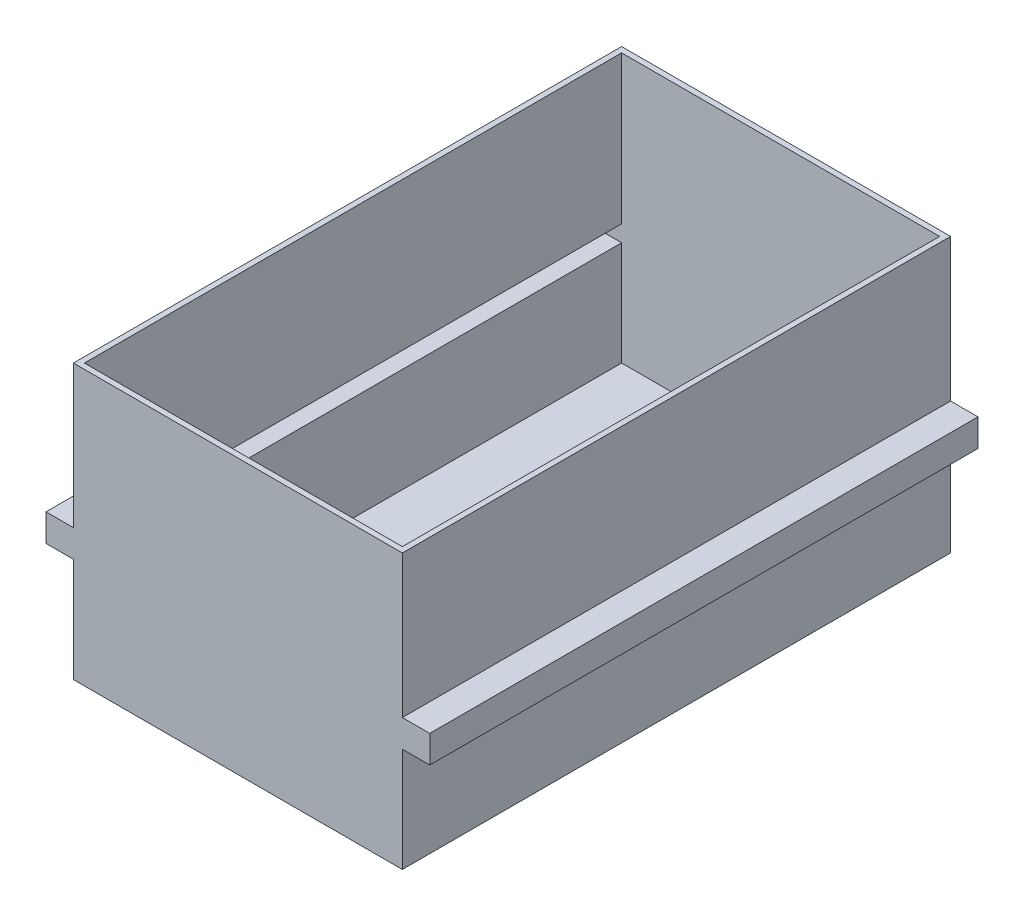
from build123d import *

# Parameters (mm, degrees)
CROQUIS1_W                   = 300
CROQUIS1_H                   = 250
SALIENTE_EXTRUIR1_DEPTH      = 500
CROQUIS3_W                   = 500
CROQUIS3_H                   = 25
SALIENTE_EXTRUIR2_DEPTH      = 25
SALIENTE_EXTRUIR2_DEPTH_BACK = 325
VACIADO1_T                   = -5


with BuildPart() as part:
    # Croquis1 → Saliente-Extruir1 (new body)
    with BuildSketch(Plane.XY):
        Rectangle(CROQUIS1_W, CROQUIS1_H)
    extrude(amount=SALIENTE_EXTRUIR1_DEPTH)

    # Croquis3 → Saliente-Extruir2 (add, two sides)
    with BuildSketch(Plane(origin=(150, 0, 0), x_dir=(0, 0, -1), z_dir=(1, 0, 0))) as saliente_extruir2_sk:
        with Locations((-250, -17.5)):
            Rectangle(CROQUIS3_W, CROQUIS3_H)
    extrude(amount=SALIENTE_EXTRUIR2_DEPTH)
    extrude(saliente_extruir2_sk.sketch, amount=-SALIENTE_EXTRUIR2_DEPTH_BACK)

    # Vaciado1
    vaciado1_openings = [part.faces().sort_by_distance(p)[0] for p in [
        (0, 125, 250),
    ]]
    offset(amount=VACIADO1_T, openings=vaciado1_openings, kind=Kind.INTERSECTION)


solid = part.part
